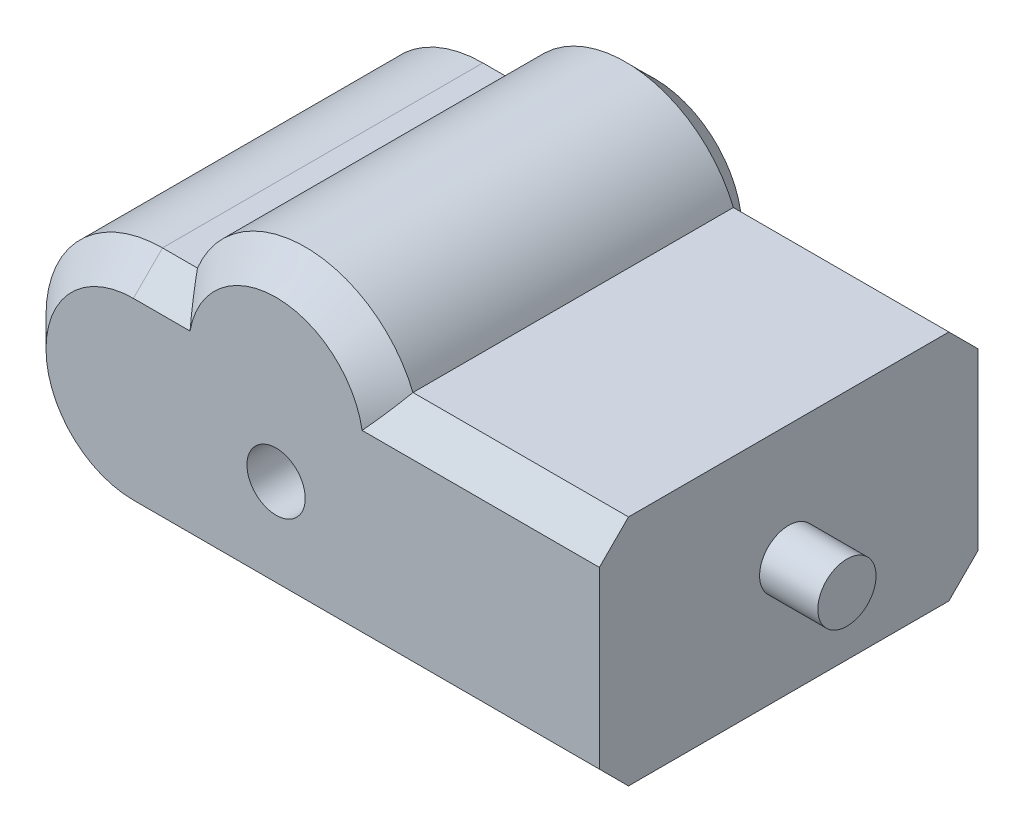
from build123d import *

# Parameters (mm, degrees)
BOSS_EXTRUDE1_DEPTH = 32.5
CHAMFER1_SIZE       = 5
SKETCH2_R           = 5
CUT_EXTRUDE1_DEPTH  = 10
SKETCH3_R           = 5
BOSS_EXTRUDE2_DEPTH = 10


with BuildPart() as part:
    # Sketch1 → Boss-Extrude1 (new body, symmetric)
    with BuildSketch(Plane.XY):
        with BuildLine():
            Line((47.428571429, 0), (47.428571429, -40))
            Line((47.428571429, -40), (-32.571428571, -40))
            ThreePointArc((-32.571428571, -40), (-52.571428571, -20), (-32.571428571, 0))
            Line((-32.571428571, 0), (-26.571428571, 0))
            ThreePointArc((-26.571428571, 0), (-8.071428571, 12.400657923), (10.428571429, 0))
            Line((10.428571429, 0), (47.428571429, 0))
        make_face()
    extrude(amount=BOSS_EXTRUDE1_DEPTH, both=True)

    # Chamfer1
    chamfer1_edges = [part.edges().sort_by_distance(p)[0] for p in [
        (28.928571429, 0, 32.5),
        (-8.071428571, 12.400657923, 32.5),
        (-29.571428571, 0, 32.5),
        (-52.571428571, -20, 32.5),
        (-29.571428571, 0, -32.5),
        (-8.071428571, 12.400657923, -32.5),
        (28.928571429, 0, -32.5),
        (7.428571429, -40, -32.5),
        (-52.571428571, -20, -32.5),
        (7.428571429, -40, 32.5),
    ]]
    chamfer(chamfer1_edges, length=CHAMFER1_SIZE)

    # Sketch2 → Cut-Extrude1 (cut)
    with BuildSketch(Plane.XY.offset(32.5)):
        with Locations((-8.071428571, -20)):
            Circle(SKETCH2_R)
    extrude(amount=-CUT_EXTRUDE1_DEPTH, mode=Mode.SUBTRACT)

    # Sketch3 → Boss-Extrude2 (add)
    with BuildSketch(Plane(origin=(47.428571429, 0, 0), x_dir=(0, 0, -1), z_dir=(1, 0, 0))):
        with Locations((0, -20)):
            Circle(SKETCH3_R)
    extrude(amount=BOSS_EXTRUDE2_DEPTH)


solid = part.part
